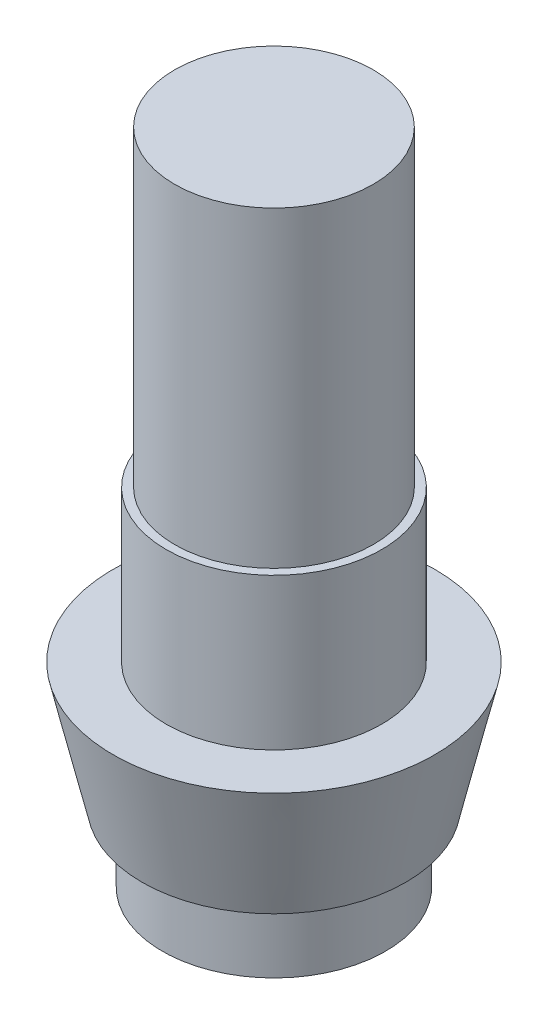
from build123d import *

# Parameters (mm, degrees)
SKETCH1_R           = 5.7
BOSS_EXTRUDE1_DEPTH = 8
SKETCH2_R           = 5.25
BOSS_EXTRUDE2_DEPTH = 16.5
SKETCH3_R           = 8.5
BOSS_EXTRUDE3_DEPTH = 6.6
BOSS_EXTRUDE3_TAPER = 13
SKETCH4_R           = 5.9
BOSS_EXTRUDE4_DEPTH = 3.7


with BuildPart() as part:
    # Sketch1 → Boss-Extrude1 (new body)
    with BuildSketch(Plane(origin=(0, 0, 0), x_dir=(1, 0, 0), z_dir=(0, 1, 0))):
        with Locations(Location((0, 0, 0), (0, 0, 270))):  # turned: the seam where the file's is
            Circle(SKETCH1_R)
    extrude(amount=BOSS_EXTRUDE1_DEPTH)

    # Sketch2 → Boss-Extrude2 (add)
    with BuildSketch(Plane(origin=(0, 8, 0), x_dir=(1, 0, 0), z_dir=(0, 1, 0))):
        with Locations(Location((0, 0, 0), (0, 0, 270))):  # turned: the seam where the file's is
            Circle(SKETCH2_R)
    extrude(amount=BOSS_EXTRUDE2_DEPTH)

    # Sketch3 → Boss-Extrude3 (add)
    with BuildSketch(Plane.XZ):
        Circle(SKETCH3_R)
    extrude(amount=BOSS_EXTRUDE3_DEPTH, taper=BOSS_EXTRUDE3_TAPER)

    # Sketch4 → Boss-Extrude4 (add)
    with BuildSketch(Plane.XZ.offset(6.6)):
        with Locations(Location((0, 0, 0), (0, 0, 270))):  # turned: the seam where the file's is
            Circle(SKETCH4_R)
    extrude(amount=BOSS_EXTRUDE4_DEPTH)


solid = part.part
